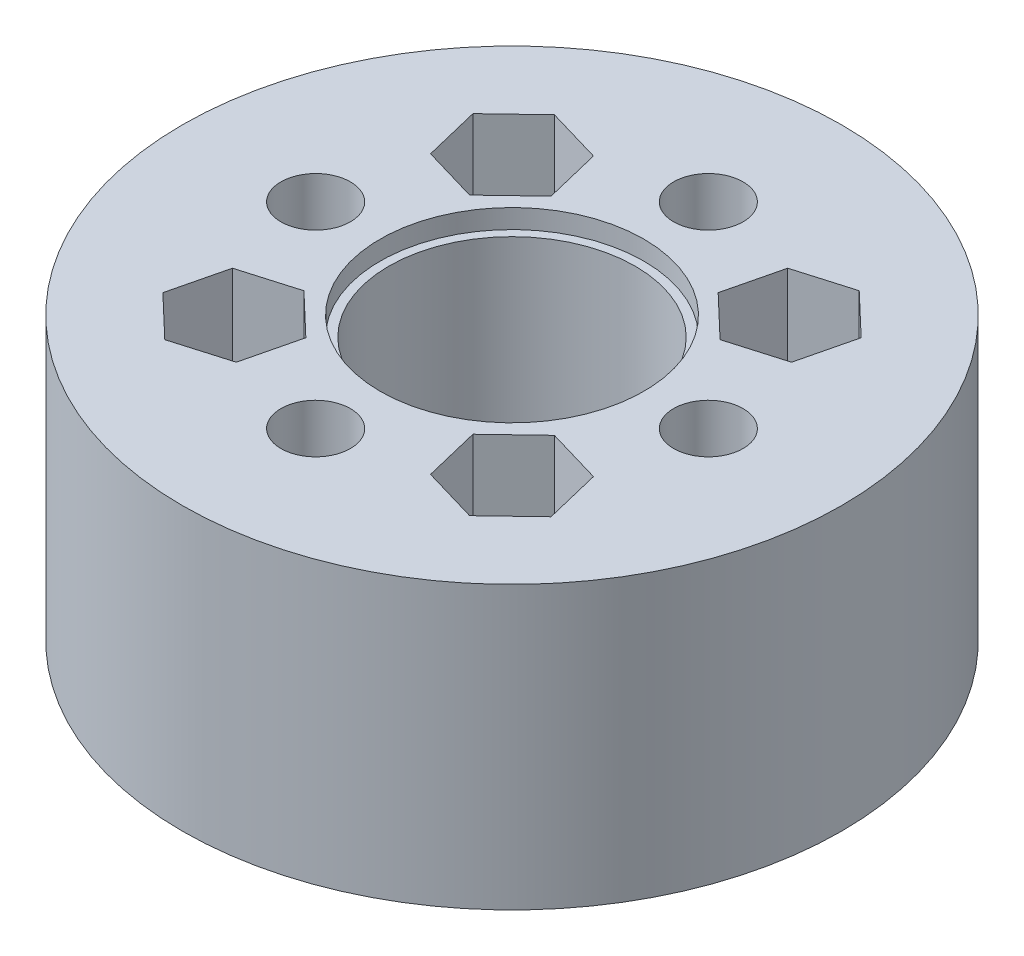
from build123d import *

# Parameters (mm, degrees)
SKETCH1_R           = 19
SKETCH1_R_2         = 2.1
SKETCH1_R_3         = 7.1
SKETCH1_R_4         = 2
BOSS_EXTRUDE1_DEPTH = 16.25
SKETCH2_R           = 7.6
CUT_EXTRUDE1_DEPTH  = 1.1
SKETCH3_R           = 7.75
CUT_EXTRUDE2_DEPTH  = 1.05
SKETCH4_R           = 2.1
CUT_EXTRUDE3_DEPTH  = 5


with BuildPart() as part:
    # Sketch1 → Boss-Extrude1 (new body)
    with BuildSketch(Plane(origin=(0, 0, 0), x_dir=(1, 0, 0), z_dir=(0, 1, 0))):
        Circle(SKETCH1_R)
        with Locations((-8, 8)):
            Circle(SKETCH1_R_2, mode=Mode.SUBTRACT)
        with Locations((-8, -8)):
            Circle(SKETCH1_R_2, mode=Mode.SUBTRACT)
        with Locations((8, 8)):
            Circle(SKETCH1_R_2, mode=Mode.SUBTRACT)
        with Locations((8, -8)):
            Circle(SKETCH1_R_2, mode=Mode.SUBTRACT)
        Circle(SKETCH1_R_3, mode=Mode.SUBTRACT)
        with Locations((0, 11.315)):
            Circle(SKETCH1_R_4, mode=Mode.SUBTRACT)
        with Locations((11.315, 0)):
            Circle(SKETCH1_R_4, mode=Mode.SUBTRACT)
        with Locations((0, -11.315)):
            Circle(SKETCH1_R_4, mode=Mode.SUBTRACT)
        with Locations((-11.315, 0)):
            Circle(SKETCH1_R_4, mode=Mode.SUBTRACT)
    extrude(amount=BOSS_EXTRUDE1_DEPTH)

    # Sketch2 → Cut-Extrude1 (cut)
    with BuildSketch(Plane(origin=(0, 16.25, 0), x_dir=(1, 0, 0), z_dir=(0, 1, 0))):
        Circle(SKETCH2_R)
    extrude(amount=-CUT_EXTRUDE1_DEPTH, mode=Mode.SUBTRACT)

    # Sketch3 → Cut-Extrude2 (cut)
    with BuildSketch(Plane.XZ):
        Circle(SKETCH3_R)
    extrude(amount=-CUT_EXTRUDE2_DEPTH, mode=Mode.SUBTRACT)

    # Sketch4 → Cut-Extrude3 (cut)
    with BuildSketch(Plane(origin=(0, 16.25, 0), x_dir=(1, 0, 0), z_dir=(0, 1, 0))):
        Polygon((-11.185438763, 8.934779773), (-10.402262411, 5.708718996), (-7.216823649, 4.773939223), (-4.814561237, 7.065220227), (-5.597737589, 10.291281004), (-8.783176351, 11.226060777), align=None)
        with Locations((-8, 8)):
            Circle(SKETCH4_R, mode=Mode.SUBTRACT)
        Polygon((7.216823649, 4.773939223), (4.814561237, 7.065220227), (5.597737589, 10.291281004), (8.783176351, 11.226060777), (11.185438763, 8.934779773), (10.402262411, 5.708718996), align=None)
        with Locations((8, 8)):
            Circle(SKETCH4_R, mode=Mode.SUBTRACT)
        Polygon((-7.216823649, -4.773939223), (-4.814561237, -7.065220227), (-5.597737589, -10.291281004), (-8.783176351, -11.226060777), (-11.185438763, -8.934779773), (-10.402262411, -5.708718996), align=None)
        with Locations((-8, -8)):
            Circle(SKETCH4_R, mode=Mode.SUBTRACT)
        Polygon((11.185438763, -8.934779773), (10.402262411, -5.708718996), (7.216823649, -4.773939223), (4.814561237, -7.065220227), (5.597737589, -10.291281004), (8.783176351, -11.226060777), align=None)
        with Locations((8, -8)):
            Circle(SKETCH4_R, mode=Mode.SUBTRACT)
    extrude(amount=-CUT_EXTRUDE3_DEPTH, mode=Mode.SUBTRACT)


solid = part.part
